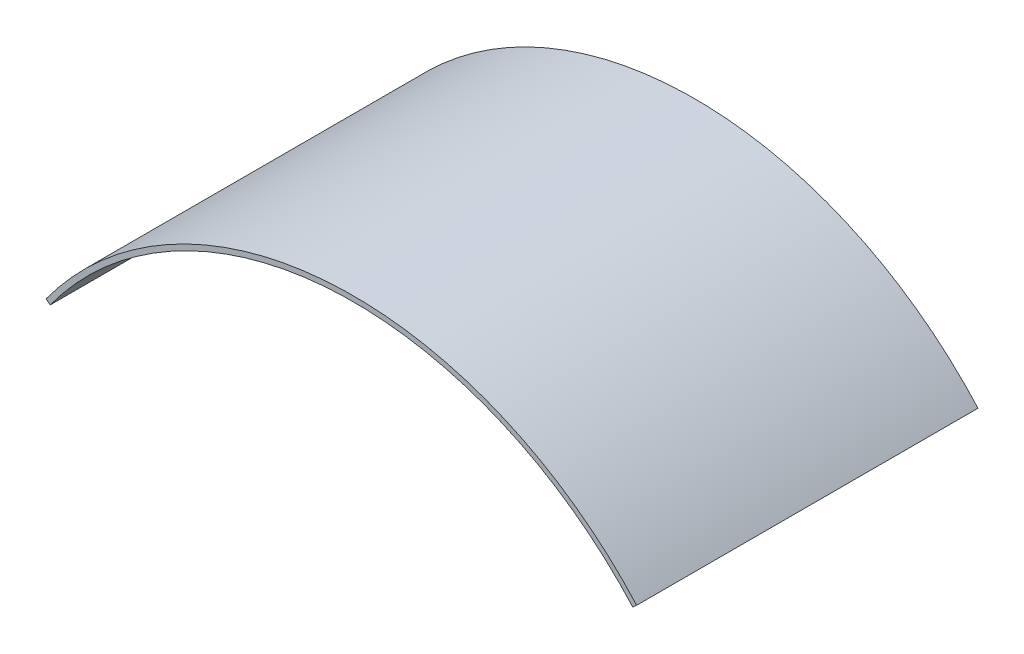
from build123d import *

# Parameters (mm, degrees)
BOSS_EXTRUDE1_DEPTH = 113.5


with BuildPart() as part:
    # Sketch1 → Boss-Extrude1 (new body)
    with BuildSketch(Plane.XY):
        with BuildLine():
            Line((0, 0), (1.414319072, -1.030631632))
            ThreePointArc((1.414319072, -1.030631632), (95.913653408, 50.08963536), (195.101622359, 8.79614068))
            Line((195.101622359, 8.79614068), (196.404368836, 9.964623292))
            ThreePointArc((196.404368836, 9.964623292), (95.824980785, 51.837387392), (0, 0))
        make_face()
    extrude(amount=BOSS_EXTRUDE1_DEPTH)


solid = part.part
